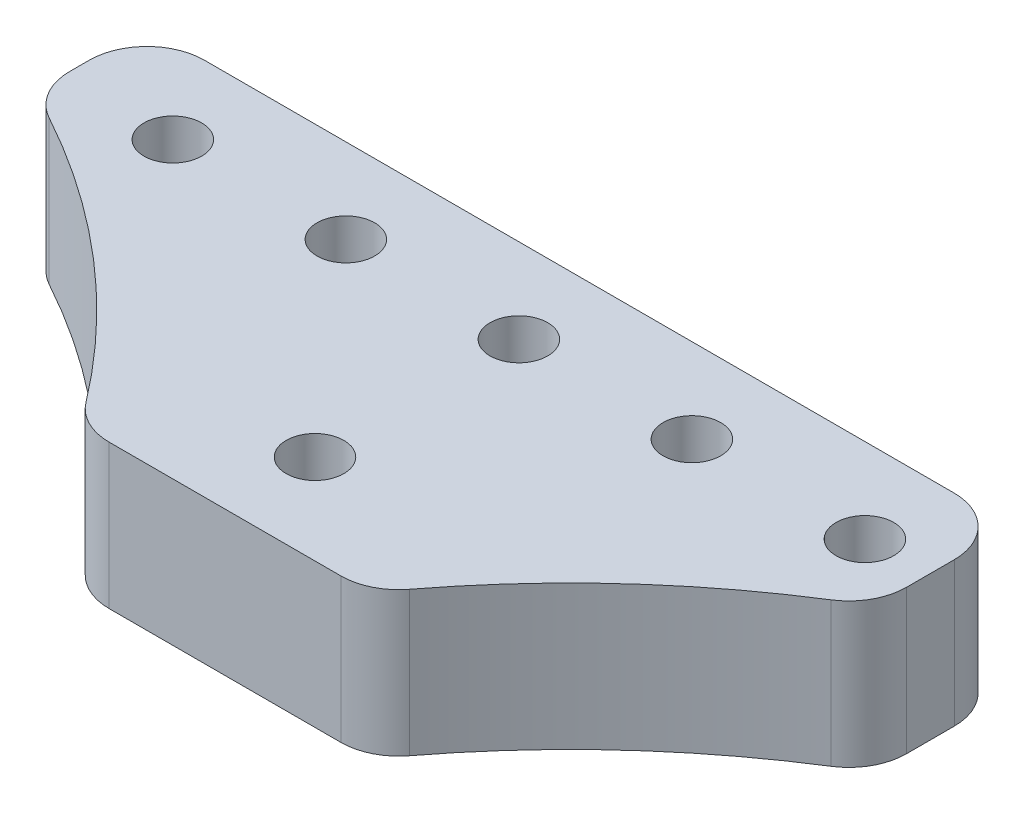
from build123d import *

# Parameters (mm, degrees)
SKETCH1_R           = 1.27
BOSS_EXTRUDE1_DEPTH = 6.35
FILLET1_R           = 2.54


with BuildPart() as part:
    # Sketch1 → Boss-Extrude1 (new body)
    with BuildSketch(Plane(origin=(0, 0, 0), x_dir=(1, 0, 0), z_dir=(0, 1, 0))):
        with BuildLine():
            Line((0, 0), (0, -4.931110589))
            ThreePointArc((0, -4.931110589), (7.586259225, -9.94755683), (13.717235362, -16.665234517))
            Line((13.717235362, -16.665234517), (26.495237193, -16.665234517))
            ThreePointArc((26.495237193, -16.665234517), (31.727577758, -10.741894012), (38.1, -6.06689826))
            Line((38.1, -6.06689826), (38.1, 0))
            Line((38.1, 0), (0, 0))
        make_face()
        with Locations((20.106236278, -12.7)):
            Circle(SKETCH1_R, mode=Mode.SUBTRACT)
        with Locations((4.866236278, -3.72093702)):
            Circle(SKETCH1_R, mode=Mode.SUBTRACT)
        with Locations((12.486236278, -3.72093702)):
            Circle(SKETCH1_R, mode=Mode.SUBTRACT)
        with Locations((20.106236278, -3.72093702)):
            Circle(SKETCH1_R, mode=Mode.SUBTRACT)
        with Locations((27.726236278, -3.72093702)):
            Circle(SKETCH1_R, mode=Mode.SUBTRACT)
        with Locations((35.346236278, -3.72093702)):
            Circle(SKETCH1_R, mode=Mode.SUBTRACT)
    extrude(amount=BOSS_EXTRUDE1_DEPTH)

    # Fillet1
    fillet1_edges = [part.edges().sort_by_distance(p)[0] for p in [
        (13.717235362, 3.175, 16.665234517),
        (0, 3.175, 4.931110589),
        (0, 3.175, 0),
        (38.1, 3.175, 0),
        (38.1, 3.175, 6.06689826),
        (26.495237193, 3.175, 16.665234517),
    ]]
    fillet(fillet1_edges, radius=FILLET1_R)


solid = part.part
